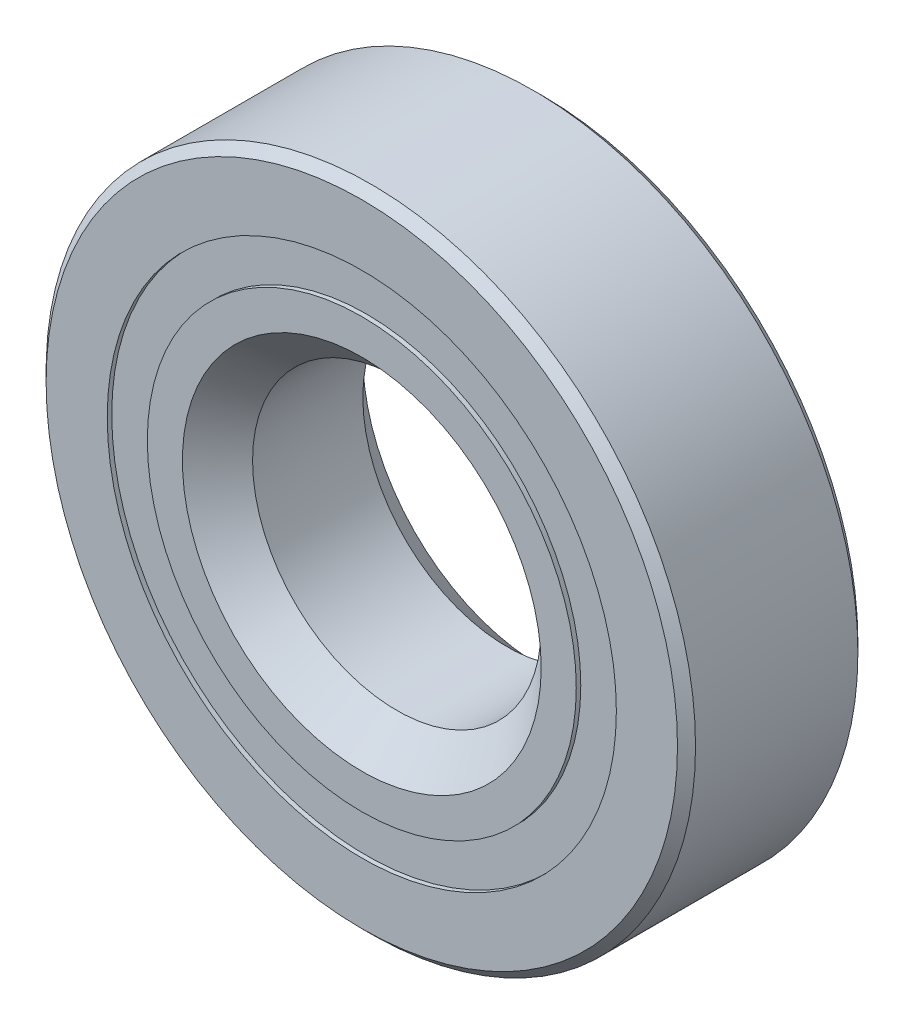
from build123d import *

# Parameters (mm, degrees)
CIRPATTERN1_COUNT = 15
SKETCH5_W         = 1.79822477
SKETCH5_H         = 1.763888888


with BuildPart() as part:
    # Sketch1 → Revolve1 (revolve)
    with BuildSketch(Plane(origin=(0, 0, 0), x_dir=(0, 0, -1), z_dir=(1, 0, 0))):
        with BuildLine():
            Line((3.571875, 14.2875), (-3.571875, 14.2875))
            Line((-3.571875, 14.2875), (-3.96875, 13.890625))
            Line((-3.96875, 13.890625), (-3.96875, 11.200694444))
            Line((-3.96875, 11.200694444), (-1.763888889, 11.200694444))
            ThreePointArc((-1.763888889, 11.200694444), (0, 12.29083773), (1.763888889, 11.200694444))
            Line((1.763888889, 11.200694444), (3.96875, 11.200694444))
            Line((3.96875, 11.200694444), (3.96875, 13.890625))
            Line((3.96875, 13.890625), (3.571875, 14.2875))
        make_face()
    revolve(axis=Axis((0, 0, 3.96875), (0, 0, -1)))


with BuildPart() as body_2:
    # Sketch2 → Revolve2 (revolve)
    with BuildSketch(Plane(origin=(0, 0, 0), x_dir=(0, 0, -1), z_dir=(1, 0, 0))):
        with BuildLine():
            Line((-3.96875, 9.436805556), (-1.763888889, 9.436805556))
            ThreePointArc((-1.763888889, 9.436805556), (0, 8.34666227), (1.763888889, 9.436805556))
            Line((1.763888889, 9.436805556), (3.96875, 9.436805556))
            Line((3.96875, 9.436805556), (3.96875, 7.893402778))
            Line((3.96875, 7.893402778), (2.425347222, 6.35))
            Line((2.425347222, 6.35), (-2.425347222, 6.35))
            Line((-2.425347222, 6.35), (-3.96875, 7.893402778))
            Line((-3.96875, 7.893402778), (-3.96875, 9.436805556))
        make_face()
    revolve(axis=Axis((0, 0, 3.96875), (0, 0, -1)))


with BuildPart() as body_3:
    # Sketch3 → Revolve3 (revolve)
    with BuildSketch(Plane(origin=(0, 0, 0), x_dir=(0, 0, -1), z_dir=(1, 0, 0))):
        with BuildLine():
            Line((-1.97208773, 10.31875), (1.97208773, 10.31875))
            ThreePointArc((1.97208773, 10.31875), (0, 12.29083773), (-1.97208773, 10.31875))
        make_face()
    revolve(axis=Axis((0, 10.31875, 1.97208773), (0, 0, -1)))


with BuildPart() as cirpattern1_1:
    # CirPattern1: pattern copy
    add(body_3.part.rotate(Axis((0, 0, -3.96875), (0, 0, 1)), 1 * 360 / CIRPATTERN1_COUNT))


with BuildPart() as cirpattern1_2:
    # CirPattern1: pattern copy
    add(body_3.part.rotate(Axis((0, 0, -3.96875), (0, 0, 1)), 2 * 360 / CIRPATTERN1_COUNT))


with BuildPart() as cirpattern1_3:
    # CirPattern1: pattern copy
    add(body_3.part.rotate(Axis((0, 0, -3.96875), (0, 0, 1)), 3 * 360 / CIRPATTERN1_COUNT))


with BuildPart() as cirpattern1_4:
    # CirPattern1: pattern copy
    add(body_3.part.rotate(Axis((0, 0, -3.96875), (0, 0, 1)), 4 * 360 / CIRPATTERN1_COUNT))


with BuildPart() as cirpattern1_5:
    # CirPattern1: pattern copy
    add(body_3.part.rotate(Axis((0, 0, -3.96875), (0, 0, 1)), 5 * 360 / CIRPATTERN1_COUNT))


with BuildPart() as cirpattern1_6:
    # CirPattern1: pattern copy
    add(body_3.part.rotate(Axis((0, 0, -3.96875), (0, 0, 1)), 6 * 360 / CIRPATTERN1_COUNT))


with BuildPart() as cirpattern1_7:
    # CirPattern1: pattern copy
    add(body_3.part.rotate(Axis((0, 0, -3.96875), (0, 0, 1)), 7 * 360 / CIRPATTERN1_COUNT))


with BuildPart() as cirpattern1_8:
    # CirPattern1: pattern copy
    add(body_3.part.rotate(Axis((0, 0, -3.96875), (0, 0, 1)), 8 * 360 / CIRPATTERN1_COUNT))


with BuildPart() as cirpattern1_9:
    # CirPattern1: pattern copy
    add(body_3.part.rotate(Axis((0, 0, -3.96875), (0, 0, 1)), 9 * 360 / CIRPATTERN1_COUNT))


with BuildPart() as cirpattern1_10:
    # CirPattern1: pattern copy
    add(body_3.part.rotate(Axis((0, 0, -3.96875), (0, 0, 1)), 10 * 360 / CIRPATTERN1_COUNT))


with BuildPart() as cirpattern1_11:
    # CirPattern1: pattern copy
    add(body_3.part.rotate(Axis((0, 0, -3.96875), (0, 0, 1)), 11 * 360 / CIRPATTERN1_COUNT))


with BuildPart() as cirpattern1_12:
    # CirPattern1: pattern copy
    add(body_3.part.rotate(Axis((0, 0, -3.96875), (0, 0, 1)), 12 * 360 / CIRPATTERN1_COUNT))


with BuildPart() as cirpattern1_13:
    # CirPattern1: pattern copy
    add(body_3.part.rotate(Axis((0, 0, -3.96875), (0, 0, 1)), 13 * 360 / CIRPATTERN1_COUNT))


with BuildPart() as cirpattern1_14:
    # CirPattern1: pattern copy
    add(body_3.part.rotate(Axis((0, 0, -3.96875), (0, 0, 1)), 14 * 360 / CIRPATTERN1_COUNT))


with BuildPart() as body_18:
    # Sketch5 → Revolve5 (revolve)
    with BuildSketch(Plane(origin=(0, 0, 0), x_dir=(0, 0, -1), z_dir=(1, 0, 0))):
        with Locations((-2.871200115, 10.31875)):
            Rectangle(SKETCH5_W, SKETCH5_H)
        with Locations((2.871200115, 10.31875)):
            Rectangle(SKETCH5_W, SKETCH5_H)
    revolve(axis=Axis((0, 0, 3.96875), (0, 0, -1)))


solid = Compound([part.part, body_2.part, body_3.part, cirpattern1_1.part, cirpattern1_2.part, cirpattern1_3.part, cirpattern1_4.part, cirpattern1_5.part, cirpattern1_6.part, cirpattern1_7.part, cirpattern1_8.part, cirpattern1_9.part, cirpattern1_10.part, cirpattern1_11.part, cirpattern1_12.part, cirpattern1_13.part, cirpattern1_14.part, body_18.part])
